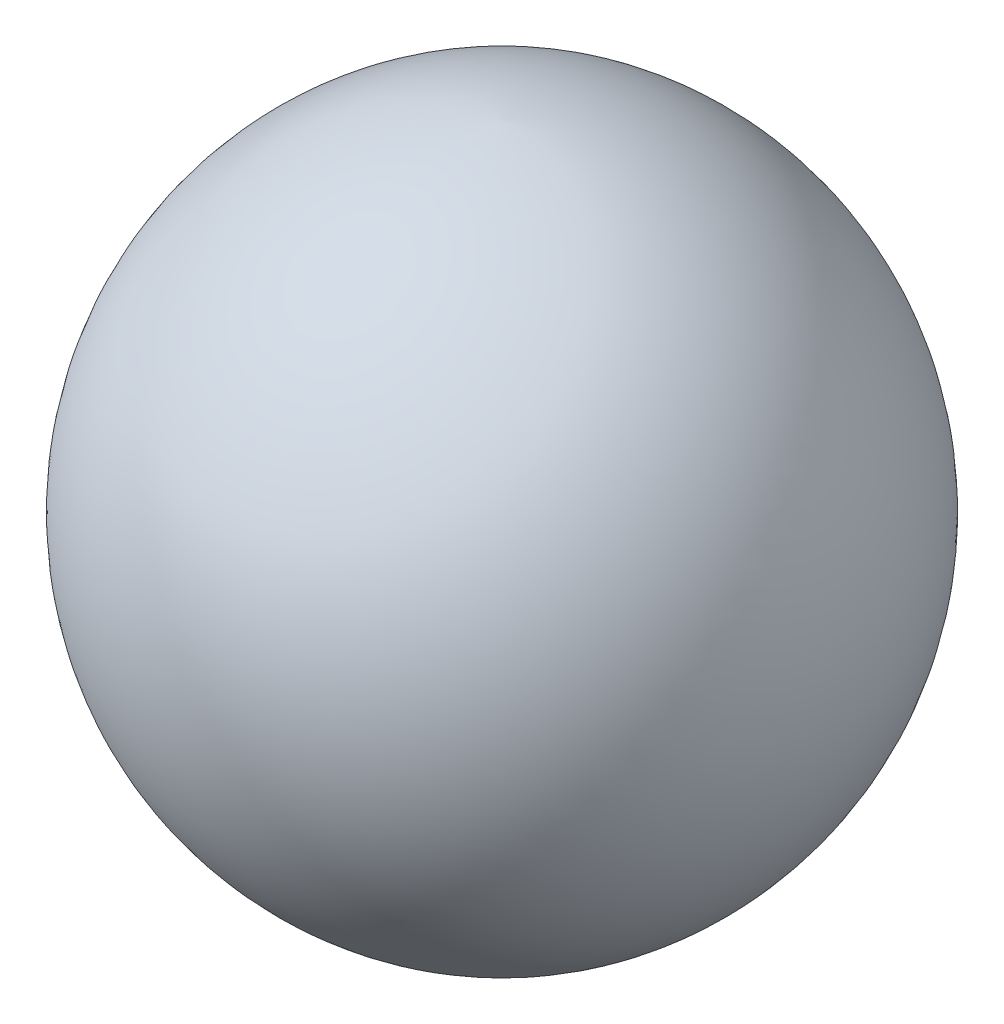
from build123d import *


with BuildPart() as part:
    # Sketch1 → Revolve1 (revolve)
    with BuildSketch(Plane.XY):
        with BuildLine():
            Line((0, 0), (0, 0.719053876))
            ThreePointArc((0, 0.719053876), (-0.341550591, 0.359526938), (0, 0))
        make_face()
    revolve(axis=Axis((0, 0, 0), (0, 1, 0)))


solid = part.part
